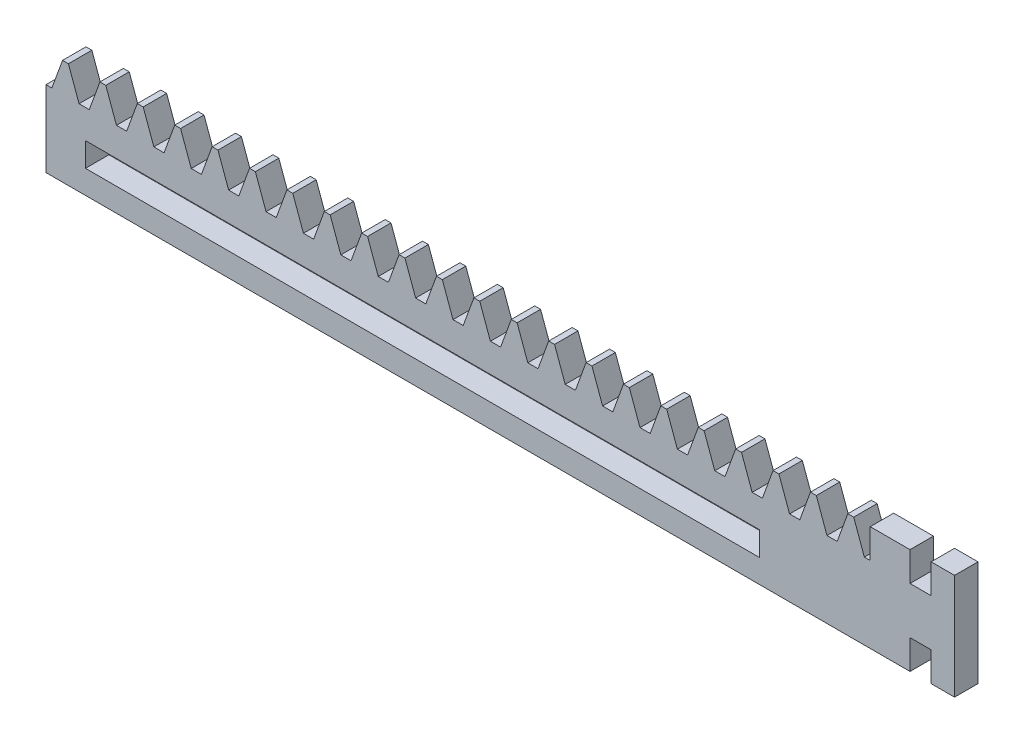
from build123d import *

# Parameters (mm, degrees)
SKIZZE1_W                       = 155
SKIZZE1_H                       = 18
AUFSATZ_LINEAR_AUSTRAGEN1_DEPTH = 4
SCHNITT_LINEAR_AUSTRAGEN1_DEPTH = 4
LINEARES_MUSTER1_COUNT          = 22
LINEARES_MUSTER1_PITCH          = 6.379656485
SCHNITT_LINEAR_AUSTRAGEN2_REACH = 6
SKIZZE3_W                       = 115
SKIZZE3_H                       = 4.1
SCHNITT_LINEAR_AUSTRAGEN3_REACH = 6
SKIZZE4_W                       = 3.6
SKIZZE4_H                       = 5


with BuildPart() as part:
    # Skizze1 → Aufsatz-Linear austragen1 (new body)
    with BuildSketch(Plane.XY):
        with Locations((77.5, 9)):
            Rectangle(SKIZZE1_W, SKIZZE1_H)
    extrude(amount=AUFSATZ_LINEAR_AUSTRAGEN1_DEPTH)

    # Skizze2 → Schnitt-Linear austragen1 (cut)
    with BuildSketch(Plane.XY.offset(4)):
        Polygon((0, 13), (1, 13), (2.819851171, 18), (0, 18), align=None)
        Polygon((3.819851171, 18), (5.639702343, 13), (6.639702343, 13), (6.639702343, 18), align=None)
    schnitt_linear_austragen1 = extrude(amount=-SCHNITT_LINEAR_AUSTRAGEN1_DEPTH, mode=Mode.SUBTRACT)

    # Lineares Muster1: Schnitt-Linear austragen1 ×22
    with Locations(*[(i * LINEARES_MUSTER1_PITCH, 0, 0) for i in range(1, LINEARES_MUSTER1_COUNT)]):
        add(schnitt_linear_austragen1, mode=Mode.SUBTRACT)

    # Skizze3 → Schnitt-Linear austragen2 (cut, up to next)
    with BuildSketch(Plane.XY.offset(4), mode=Mode.PRIVATE) as schnitt_linear_austragen2_sk1:
        with Locations((64.227564671, 6.05)):
            Rectangle(SKIZZE3_W, SKIZZE3_H)
    schnitt_linear_austragen2_tool1 = extrude(schnitt_linear_austragen2_sk1.sketch, amount=-SCHNITT_LINEAR_AUSTRAGEN2_REACH, mode=Mode.PRIVATE) & part.part
    add(schnitt_linear_austragen2_tool1.solids().sort_by_distance((64.227565, 6.05, 4))[0], mode=Mode.SUBTRACT)

    # Skizze4 → Schnitt-Linear austragen3 (cut, up to next)
    with BuildSketch(Plane.XY.offset(4), mode=Mode.PRIVATE) as schnitt_linear_austragen3_sk1:
        with Locations((149.2, 15.5)):
            Rectangle(SKIZZE4_W, SKIZZE4_H)
    schnitt_linear_austragen3_tool1 = extrude(schnitt_linear_austragen3_sk1.sketch, amount=-SCHNITT_LINEAR_AUSTRAGEN3_REACH, mode=Mode.PRIVATE) & part.part
    add(schnitt_linear_austragen3_tool1.solids().sort_by_distance((149.2, 15.5, 4))[0], mode=Mode.SUBTRACT)
    # Skizze4 → Schnitt-Linear austragen3 (cut, up to next)
    with BuildSketch(Plane.XY.offset(4), mode=Mode.PRIVATE) as schnitt_linear_austragen3_sk2:
        with Locations((149.2, 2.5)):
            Rectangle(SKIZZE4_W, SKIZZE4_H)
    schnitt_linear_austragen3_tool2 = extrude(schnitt_linear_austragen3_sk2.sketch, amount=-SCHNITT_LINEAR_AUSTRAGEN3_REACH, mode=Mode.PRIVATE) & part.part
    add(schnitt_linear_austragen3_tool2.solids().sort_by_distance((149.2, 2.5, 4))[0], mode=Mode.SUBTRACT)


solid = part.part
